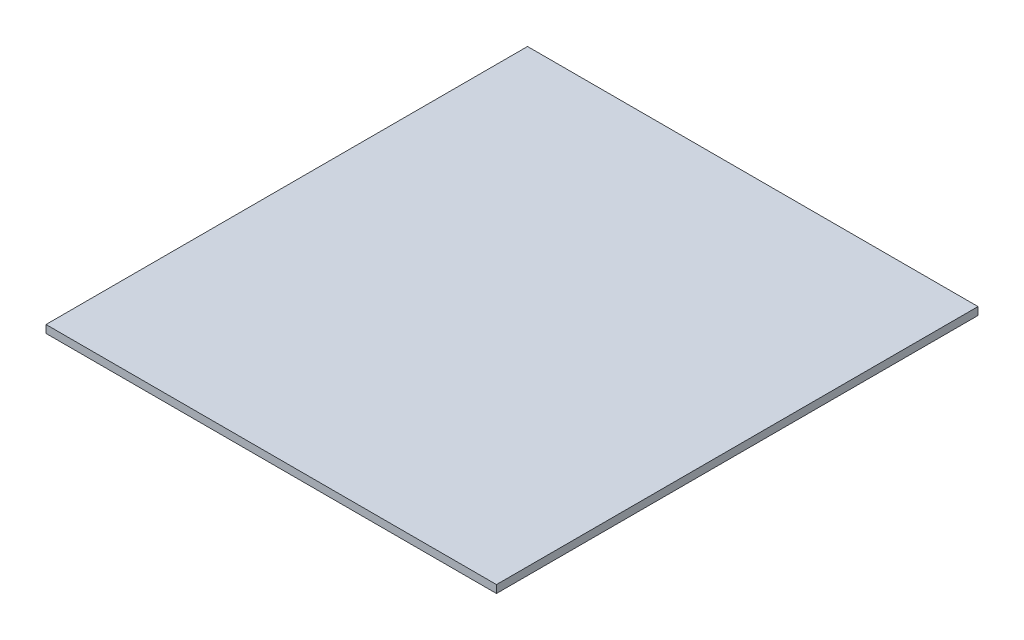
from build123d import *

# Parameters (mm, degrees)
SKETCH1_W           = 368.3
SKETCH1_H           = 393.7
BOSS_EXTRUDE1_DEPTH = 6.35


with BuildPart() as part:
    # Sketch1 → Boss-Extrude1 (new body)
    with BuildSketch(Plane(origin=(0, 0, 0), x_dir=(1, 0, 0), z_dir=(0, 1, 0))):
        Rectangle(SKETCH1_W, SKETCH1_H)
    extrude(amount=BOSS_EXTRUDE1_DEPTH)


solid = part.part
